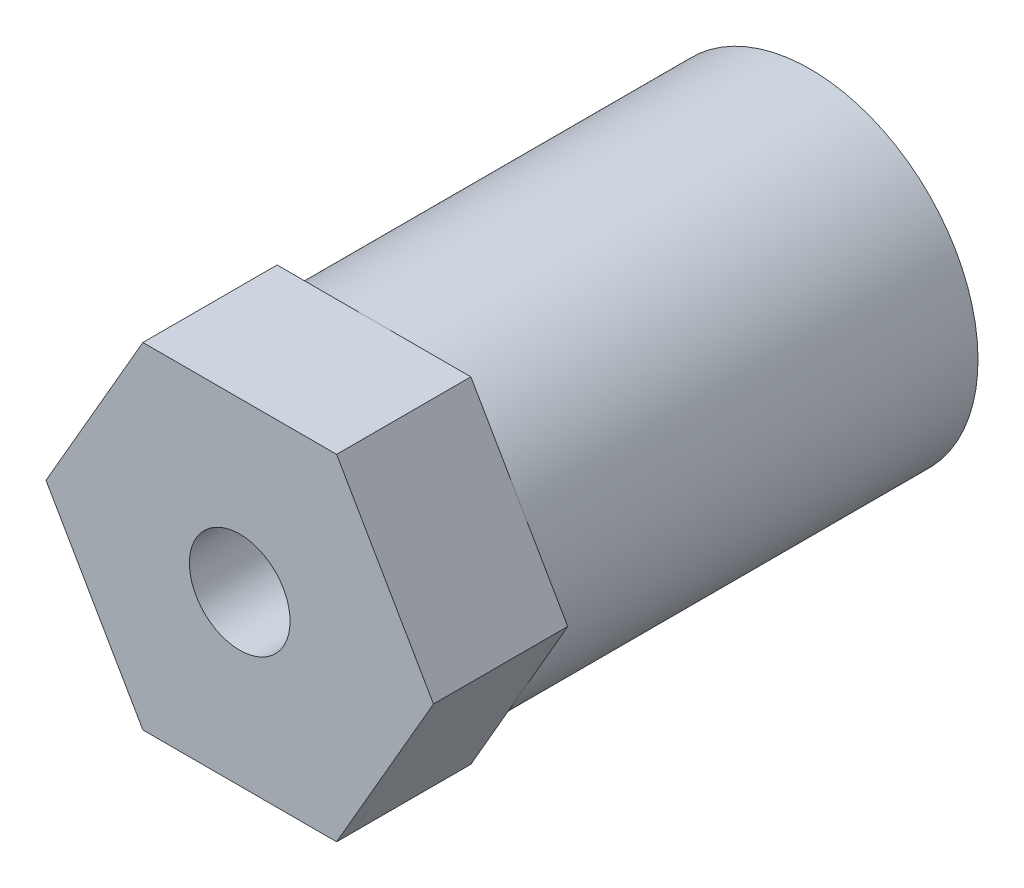
from build123d import *

# Parameters (mm, degrees)
CROQUIS2_R              = 1.5
SALIENTE_EXTRUIR1_DEPTH = 4
CROQUIS3_R              = 5
CROQUIS3_R_2            = 2.5
SALIENTE_EXTRUIR2_DEPTH = 13


with BuildPart() as part:
    # Croquis2 → Saliente-Extruir1 (new body)
    with BuildSketch(Plane.XY):
        Polygon((2.886751346, 5), (-2.886751346, 5), (-5.773502692, 0), (-2.886751346, -5), (2.886751346, -5), (5.773502692, 0), align=None)
        Circle(CROQUIS2_R, mode=Mode.SUBTRACT)
    extrude(amount=SALIENTE_EXTRUIR1_DEPTH)

    # Croquis3 → Saliente-Extruir2 (add)
    with BuildSketch(Plane(origin=(0, 0, 0), x_dir=(-1, 0, 0), z_dir=(0, 0, -1))):
        Circle(CROQUIS3_R)
        Circle(CROQUIS3_R_2, mode=Mode.SUBTRACT)
    extrude(amount=SALIENTE_EXTRUIR2_DEPTH)


solid = part.part
